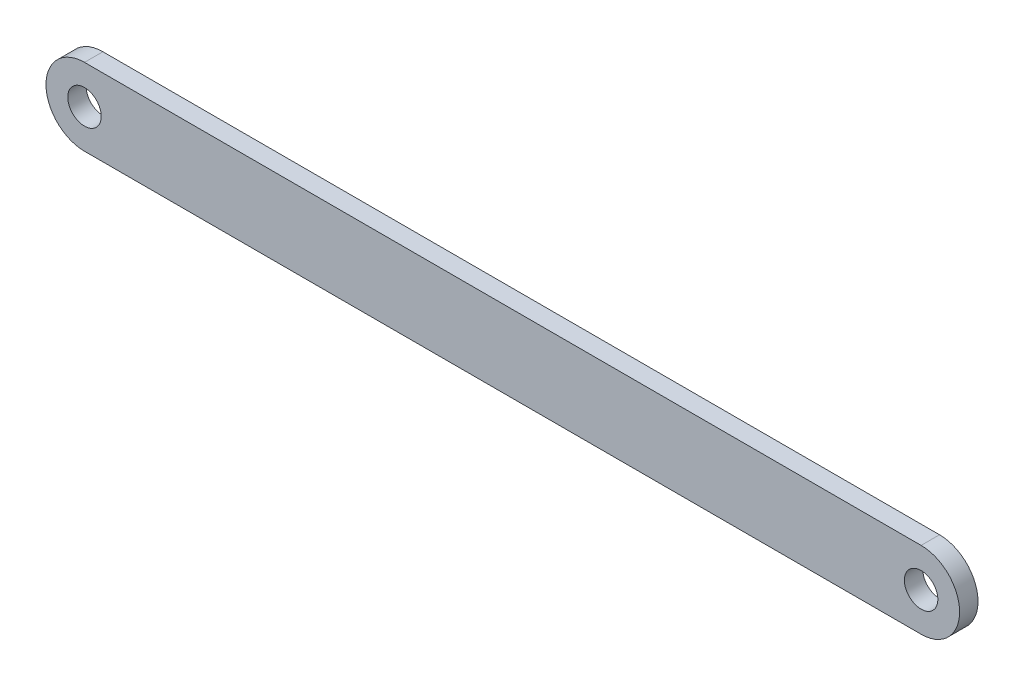
from build123d import *

# Parameters (mm, degrees)
SKETCH1_R        = 5
LINK_CD_JH_DEPTH = 2.75


with BuildPart() as part:
    # Sketch1 → link_CD_JH (new body, symmetric)
    with BuildSketch(Plane.XY):
        with BuildLine():
            Line((-125, 11.5), (125, 11.5))
            ThreePointArc((125, 11.5), (136.5, 0), (125, -11.5))
            Line((125, -11.5), (-125, -11.5))
            ThreePointArc((-125, -11.5), (-136.5, 0), (-125, 11.5))
        make_face()
        with Locations((-125, 0)):
            Circle(SKETCH1_R, mode=Mode.SUBTRACT)
        with Locations((125, 0)):
            Circle(SKETCH1_R, mode=Mode.SUBTRACT)
    extrude(amount=LINK_CD_JH_DEPTH, both=True)


solid = part.part
